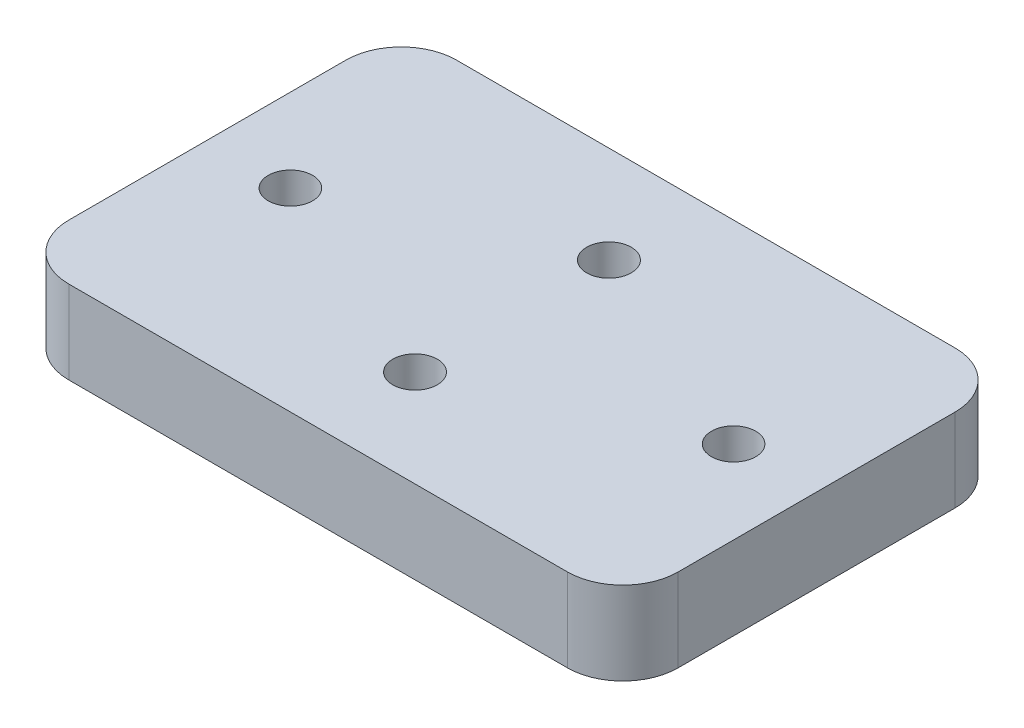
from build123d import *

# Parameters (mm, degrees)
SKETCH1_W                                          = 69.85
SKETCH1_H                                          = 44.45
BOSS_EXTRUDE1_DEPTH                                = 9.525
CSK_FOR_10_FLAT_HEAD_MACHINE_SCREW_100_D           = 5.1054
CSK_FOR_10_FLAT_HEAD_MACHINE_SCREW_100_CSINK_D     = 9.779
CSK_FOR_10_FLAT_HEAD_MACHINE_SCREW_100_CSINK_ANGLE = 82
F_10_0_2_DIAMETER_HOLE1_D                          = 5.08
FILLET4_R                                          = 6.35


with BuildPart() as part:
    # Sketch1 → Boss-Extrude1 (new body)
    with BuildSketch(Plane(origin=(0, 0, 0), x_dir=(1, 0, 0), z_dir=(0, 1, 0))):
        Rectangle(SKETCH1_W, SKETCH1_H)
    extrude(amount=BOSS_EXTRUDE1_DEPTH)

    # CSK for #10 Flat Head Machine Screw (100)1 (through all)
    with Locations(Plane(origin=(0, 0, 0), x_dir=(-1, 0, 0), z_dir=(0, -1, 0))):
        with Locations((0, 11.1125), (0, -11.1125)):
            CounterSinkHole(CSK_FOR_10_FLAT_HEAD_MACHINE_SCREW_100_D / 2, CSK_FOR_10_FLAT_HEAD_MACHINE_SCREW_100_CSINK_D / 2, counter_sink_angle=CSK_FOR_10_FLAT_HEAD_MACHINE_SCREW_100_CSINK_ANGLE)

    # #10 (0.2) Diameter Hole1 (through all)
    with Locations(Plane(origin=(0, 0, 0), x_dir=(-1, 0, 0), z_dir=(0, -1, 0))):
        with Locations((-25.4, 0)):
            f_10_0_2_diameter_hole1 = Hole(F_10_0_2_DIAMETER_HOLE1_D / 2)

    # Mirror1: #10 (0.2) Diameter Hole1 across plane
    add(f_10_0_2_diameter_hole1.mirror(Plane(origin=(0, 0, 0), x_dir=(0, 0, 1), z_dir=(1, 0, 0))), mode=Mode.SUBTRACT)

    # Fillet4
    fillet4_edges = [part.edges().sort_by_distance(p)[0] for p in [
        (34.925, 4.7625, 22.225),
        (-34.925, 4.7625, 22.225),
        (-34.925, 4.7625, -22.225),
        (34.925, 4.7625, -22.225),
    ]]
    fillet(fillet4_edges, radius=FILLET4_R)


solid = part.part
